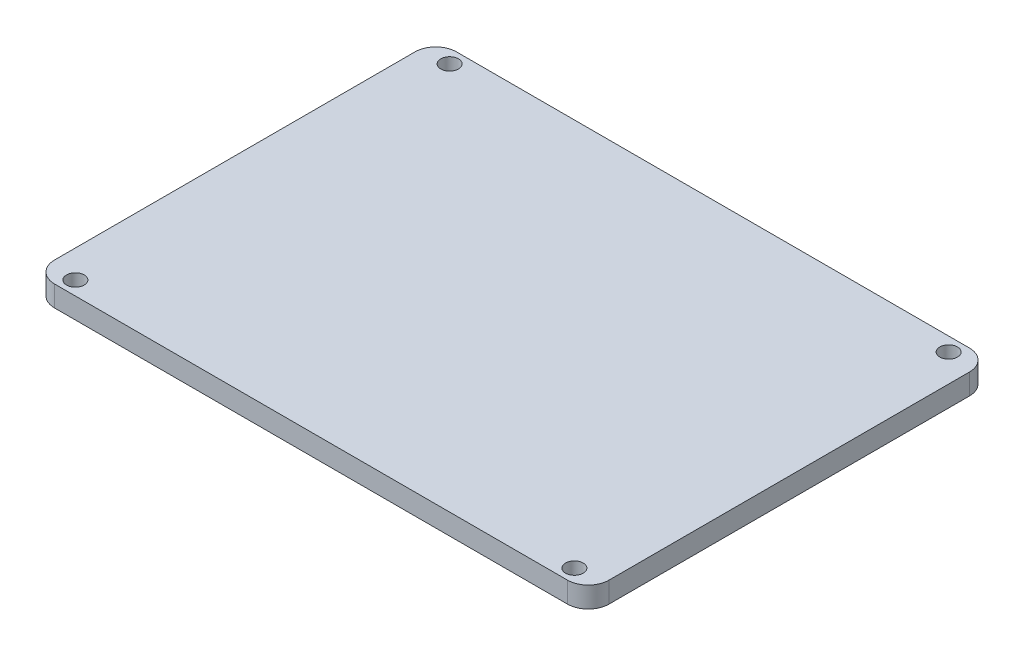
from build123d import *

# Parameters (mm, degrees)
SKETCH_1_W               = 80
SKETCH_1_H               = 58
EXTRUDE_1_DEPTH          = 3
SKETCH_2_R               = 1.275
CUT_EXTRUDE_1_DEPTH      = 1
CUT_EXTRUDE_1_DEPTH_BACK = 4
FILLET_1_R               = 3


with BuildPart() as part:
    # 草图1 → 凸台-拉伸1 (new body)
    with BuildSketch(Plane(origin=(0, 0, 0), x_dir=(1, 0, 0), z_dir=(0, 1, 0))):
        Rectangle(SKETCH_1_W, SKETCH_1_H)
    extrude(amount=EXTRUDE_1_DEPTH)

    # 草图2 → 切除-拉伸1 (cut, two sides)
    with BuildSketch(Plane(origin=(0, 3, 0), x_dir=(1, 0, 0), z_dir=(0, 1, 0))) as cut_extrude_1_sk:
        with Locations((36, -27)):
            Circle(SKETCH_2_R)
        with Locations((36, 27)):
            Circle(SKETCH_2_R)
        with Locations((-36, 27)):
            Circle(SKETCH_2_R)
        with Locations((-36, -27)):
            Circle(SKETCH_2_R)
    extrude(amount=CUT_EXTRUDE_1_DEPTH, mode=Mode.SUBTRACT)
    extrude(cut_extrude_1_sk.sketch, amount=-CUT_EXTRUDE_1_DEPTH_BACK, mode=Mode.SUBTRACT)

    # 圆角1
    fillet_1_edges = [part.edges().sort_by_distance(p)[0] for p in [
        (40, 1.5, 29),
        (-40, 1.5, 29),
        (-40, 1.5, -29),
        (40, 1.5, -29),
    ]]
    fillet(fillet_1_edges, radius=FILLET_1_R)


solid = part.part
